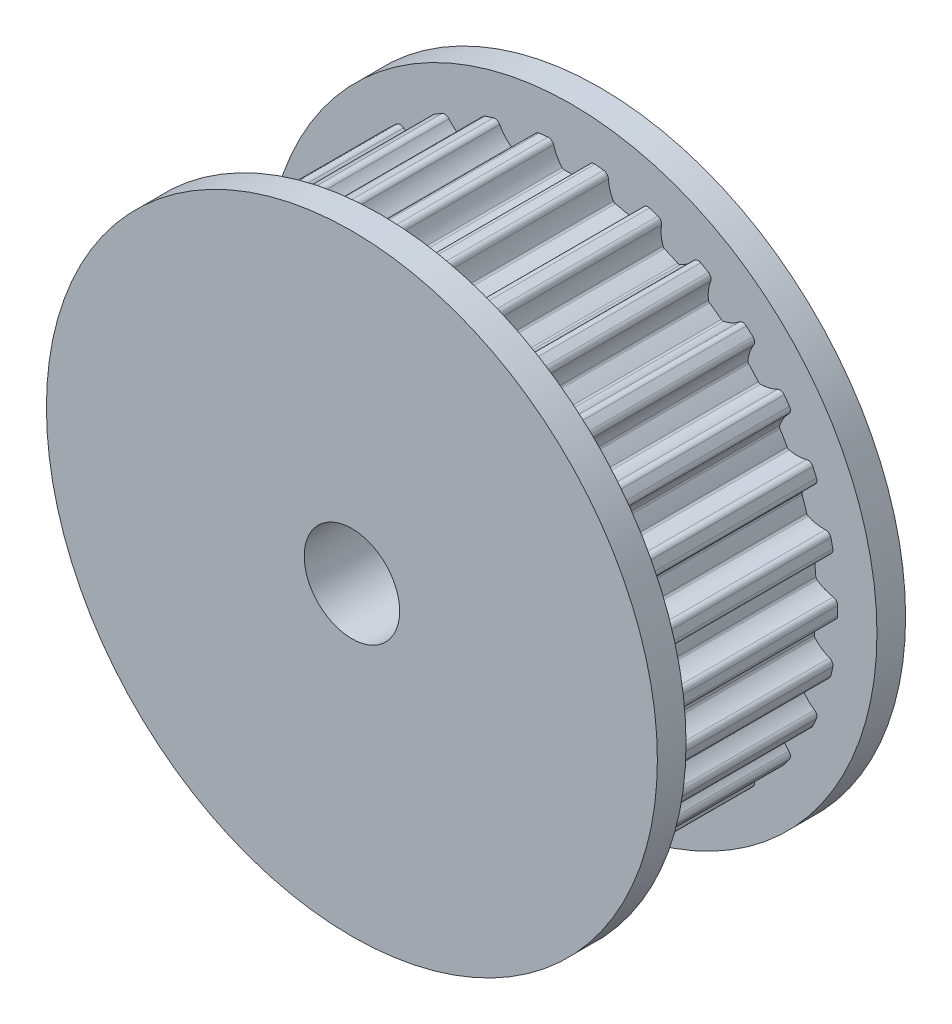
from build123d import *

# Parameters (mm, degrees)
SKETCH_1_R               = 13.945
EXTRUDE_1_DEPTH          = 5
CUT_EXTRUDE_1_DEPTH      = 23.111672257
PATTERN_CIRCULAR_1_COUNT = 30
SKETCH_3_R               = 16
EXTRUDE_2_DEPTH          = 1.5
EXTRUDE_START            = 1.5
SKETCH_9_R               = 16
EXTRUDE_3_DEPTH          = 1.5
CUT_EXTRUDE_2_DEPTH      = 8
CUT_EXTRUDE_2_DEPTH_BACK = 27.095976701
SKETCH_4_R               = 2.5
SKETCH_10_R              = 2
CUT_EXTRUDE_3_DEPTH      = 24.542514734
SKETCH_11_R              = 2
CUT_EXTRUDE_4_DEPTH      = 24.542514762


with BuildPart() as part:
    # 草圖1 → 填料-伸長1 (new, symmetric)
    with BuildSketch(Plane.XY):
        Circle(SKETCH_1_R)
    extrude(amount=EXTRUDE_1_DEPTH, both=True)

    # 草圖2 → 除料-伸長1 (cut, symmetric)
    with BuildSketch(Plane.XY.offset(5)):
        with BuildLine():
            ThreePointArc((-0.378191206, 12.829426971), (0, 12.835), (0.378191206, 12.829426971))
            ThreePointArc((0.378191206, 12.829426971), (0.441673339, 12.841479116), (0.494195519, 12.879117608))
            ThreePointArc((0.494195519, 12.879117608), (0.760467696, 13.256250364), (0.931913991, 13.684894922))
            ThreePointArc((0.931913991, 13.684894922), (1.041931637, 13.841561752), (1.22689599, 13.89092334))
            ThreePointArc((1.22689599, 13.89092334), (0, 13.945), (-1.22689599, 13.89092334))
            ThreePointArc((-1.22689599, 13.89092334), (-1.041931637, 13.841561752), (-0.931913991, 13.684894922))
            ThreePointArc((-0.931913991, 13.684894922), (-0.760467696, 13.256250364), (-0.494195519, 12.879117608))
            ThreePointArc((-0.494195519, 12.879117608), (-0.441673339, 12.841479116), (-0.378191206, 12.829426971))
        make_face()
    cut_extrude_1 = extrude(amount=CUT_EXTRUDE_1_DEPTH, both=True, mode=Mode.SUBTRACT)

    # 環狀複製排列1: 除料-伸長1 ×30 about axis
    pattern_circular_1_axis = Axis((0, 0, 5), (0, 0, -1))
    for i in range(1, PATTERN_CIRCULAR_1_COUNT):
        add(cut_extrude_1.rotate(pattern_circular_1_axis, i * 360 / PATTERN_CIRCULAR_1_COUNT), mode=Mode.SUBTRACT)

    # 草圖3 → 填料-伸長2 (add)
    with BuildSketch(Plane.XY.offset(5)):
        Circle(SKETCH_3_R)
    extrude(amount=EXTRUDE_2_DEPTH)

    # 草圖9 → 填料-伸長3 (add)
    with BuildSketch(Plane(origin=(0, 0, -5), x_dir=(-1, 0, 0), z_dir=(0, 0, -1)).offset(EXTRUDE_START)):
        Circle(SKETCH_9_R)
    extrude(amount=-EXTRUDE_3_DEPTH)

    # 草圖4 → 除料-伸長2 (cut, two sides: drawn at the far end of the back side and taken through both)
    with BuildSketch(Plane.XY.offset(6.5).offset(-CUT_EXTRUDE_2_DEPTH_BACK)):
        Circle(SKETCH_4_R)
    extrude(amount=CUT_EXTRUDE_2_DEPTH + CUT_EXTRUDE_2_DEPTH_BACK, mode=Mode.SUBTRACT)

    # 草圖10 → 除料-伸長3 (cut, through all)
    with BuildSketch(Plane(origin=(0, 0, 0), x_dir=(1, 0, 0), z_dir=(0, 1, 0))):
        Circle(SKETCH_10_R)
    extrude(amount=-CUT_EXTRUDE_3_DEPTH, mode=Mode.SUBTRACT)

    # 草圖11 → 除料-伸長4 (cut, through all)
    with BuildSketch(Plane(origin=(0, 0, 0), x_dir=(0, 0, -1), z_dir=(1, 0, 0))):
        Circle(SKETCH_11_R)
    extrude(amount=-CUT_EXTRUDE_4_DEPTH, mode=Mode.SUBTRACT)


solid = part.part
